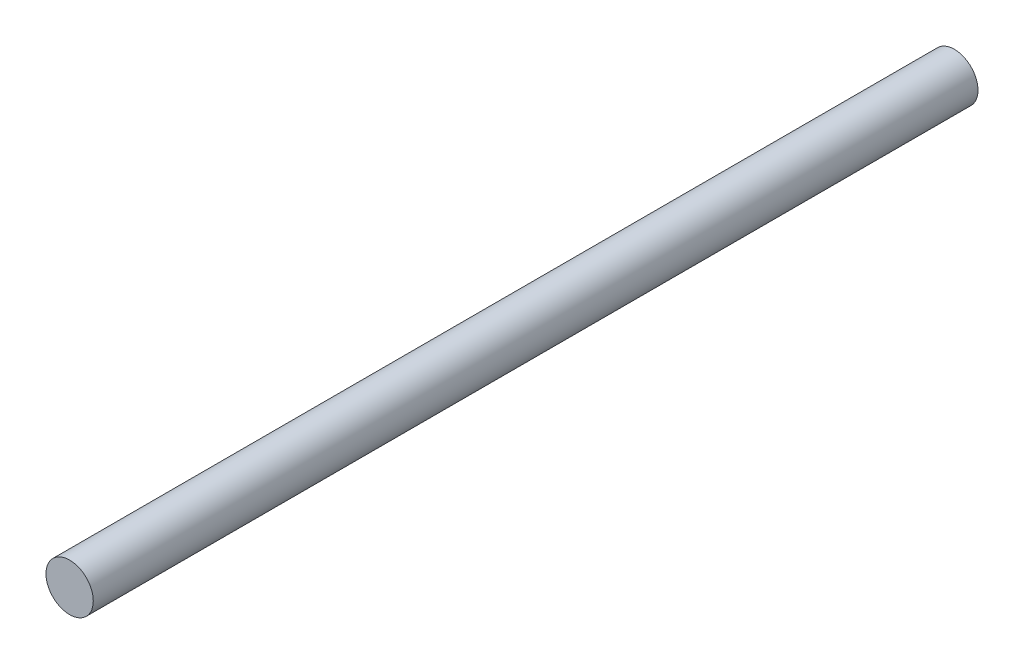
from build123d import *

# Parameters (mm, degrees)
SKETCH1_R           = 11.5
BOSS_EXTRUDE1_DEPTH = 215


with BuildPart() as part:
    # Sketch1 → Boss-Extrude1 (new body, symmetric)
    with BuildSketch(Plane.XY):
        Circle(SKETCH1_R)
    extrude(amount=BOSS_EXTRUDE1_DEPTH, both=True)


solid = part.part
